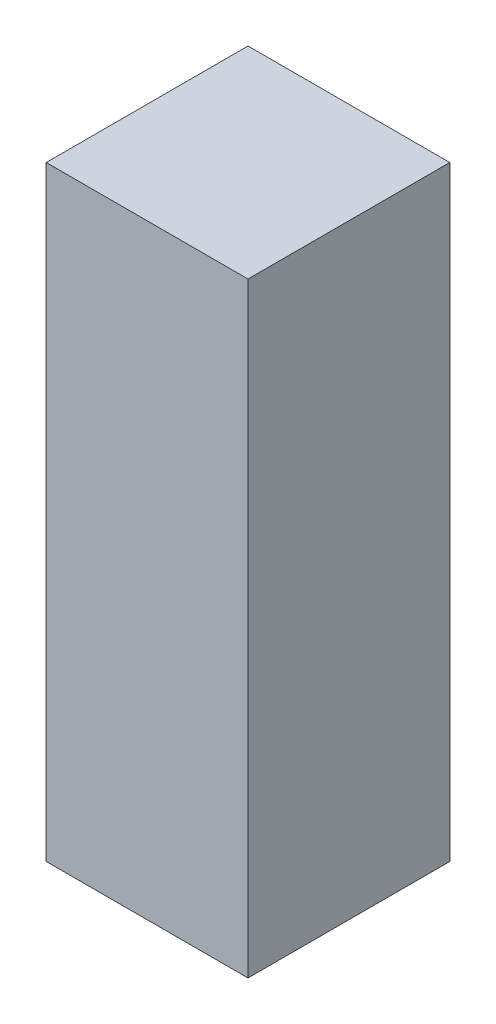
from build123d import *

# Parameters (mm, degrees)
SKETCH1_W           = 50
SKETCH1_H           = 50
BOSS_EXTRUDE1_DEPTH = 150
SKETCH2_R           = 15
CUT_EXTRUDE1_DEPTH  = 100


with BuildPart() as part:
    # Sketch1 → Boss-Extrude1 (new body)
    with BuildSketch(Plane(origin=(0, 0, 0), x_dir=(1, 0, 0), z_dir=(0, 1, 0))):
        with Locations((-27.798692914, 7.251418332)):
            Rectangle(SKETCH1_W, SKETCH1_H)
    extrude(amount=BOSS_EXTRUDE1_DEPTH)

    # Sketch2 → Cut-Extrude1 (cut)
    with BuildSketch(Plane.XZ):
        with Locations((-27.798692914, -7.251418332)):
            Circle(SKETCH2_R)
    extrude(amount=-CUT_EXTRUDE1_DEPTH, mode=Mode.SUBTRACT)


solid = part.part
